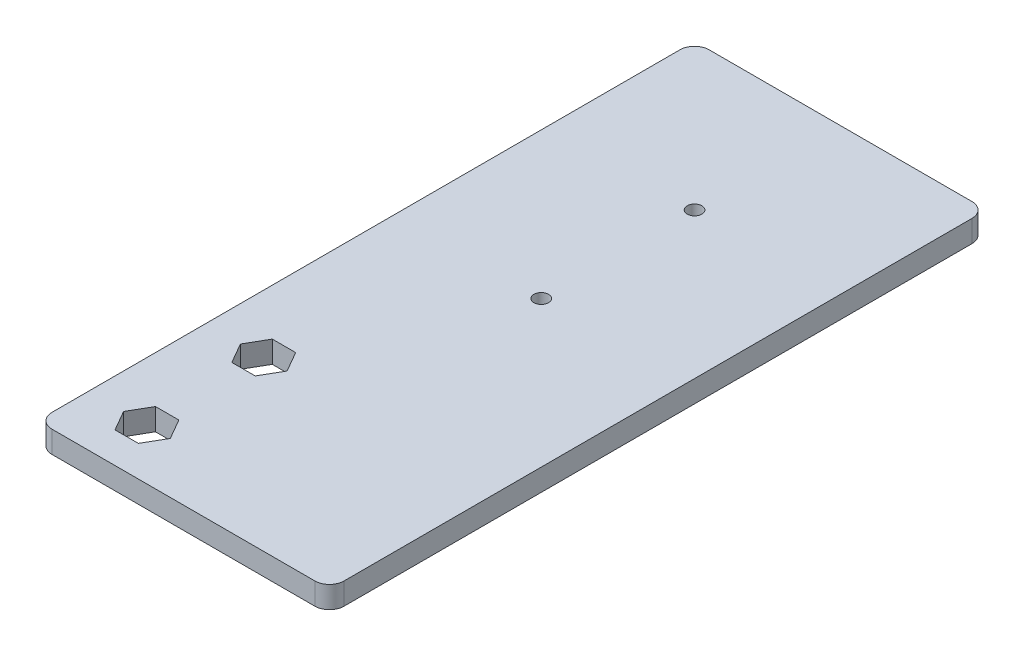
from build123d import *

# Parameters (mm, degrees)
EXTRUSION1_DEPTH        = 3
ESQUISSE2_R             = 1.1
ENL_V_MAT_EXTRU_1_DEPTH = 4
ESQUISSE3_R             = 1
ENL_V_MAT_EXTRU_2_DEPTH = 4


with BuildPart() as part:
    # Esquisse1 → Extrusion1 (new body)
    with BuildSketch(Plane(origin=(0, 0, 0), x_dir=(1, 0, 0), z_dir=(0, 1, 0))):
        with BuildLine():
            Line((13, 2), (13, 88))
            ThreePointArc((13, 88), (13.585786438, 89.414213562), (15, 90))
            Line((15, 90), (51, 90))
            ThreePointArc((51, 90), (52.414213562, 89.414213562), (53, 88))
            Line((53, 88), (53, 2))
            ThreePointArc((53, 2), (52.414213562, 0.585786438), (51, 0))
            Line((51, 0), (15, 0))
            ThreePointArc((15, 0), (13.585786438, 0.585786438), (13, 2))
        make_face()
    extrude(amount=EXTRUSION1_DEPTH)

    # Esquisse2 → Enlèv. mat.-Extru.1 (cut, through all)
    with BuildSketch(Plane.XZ):
        with Locations(Location((21, -7, 0), (0, 0, 90))):  # turned: the seam where the file's is
            Circle(ESQUISSE2_R)
        with Locations(Location((21, -23, 0), (0, 0, 90))):  # turned: the seam where the file's is
            Circle(ESQUISSE2_R)
    extrude(amount=-ENL_V_MAT_EXTRU_1_DEPTH, mode=Mode.SUBTRACT)

    # Esquisse3 → Enlèv. mat.-Extru.2 (cut, through all)
    with BuildSketch(Plane(origin=(0, 3, 0), x_dir=(1, 0, 0), z_dir=(0, 1, 0))):
        with Locations(Location((33, 70, 0), (0, 0, 270))):  # turned: the seam where the file's is
            Circle(ESQUISSE3_R)
        with Locations(Location((33, 49, 0), (0, 0, 270))):  # turned: the seam where the file's is
            Circle(ESQUISSE3_R)
        Polygon((17.8, 23), (19.4, 20.228718708), (22.6, 20.228718708), (24.2, 23), (22.6, 25.771281292), (19.4, 25.771281292), align=None)
        Polygon((17.8, 7), (19.4, 4.228718708), (22.6, 4.228718708), (24.2, 7), (22.6, 9.771281292), (19.4, 9.771281292), align=None)
    extrude(amount=-ENL_V_MAT_EXTRU_2_DEPTH, mode=Mode.SUBTRACT)


solid = part.part
